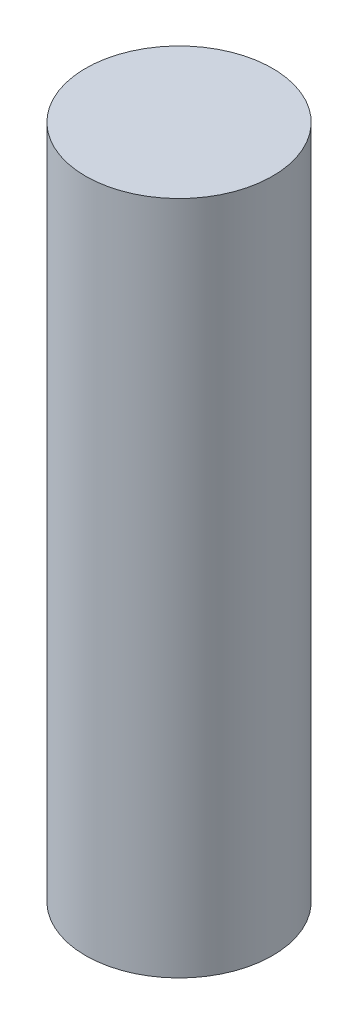
from build123d import *

# Parameters (mm, degrees)
SKETCH1_R           = 9
BOSS_EXTRUDE1_DEPTH = 65


with BuildPart() as part:
    # Sketch1 → Boss-Extrude1 (new body)
    with BuildSketch(Plane(origin=(0, 0, 0), x_dir=(1, 0, 0), z_dir=(0, 1, 0))):
        Circle(SKETCH1_R)
    extrude(amount=BOSS_EXTRUDE1_DEPTH)


solid = part.part
